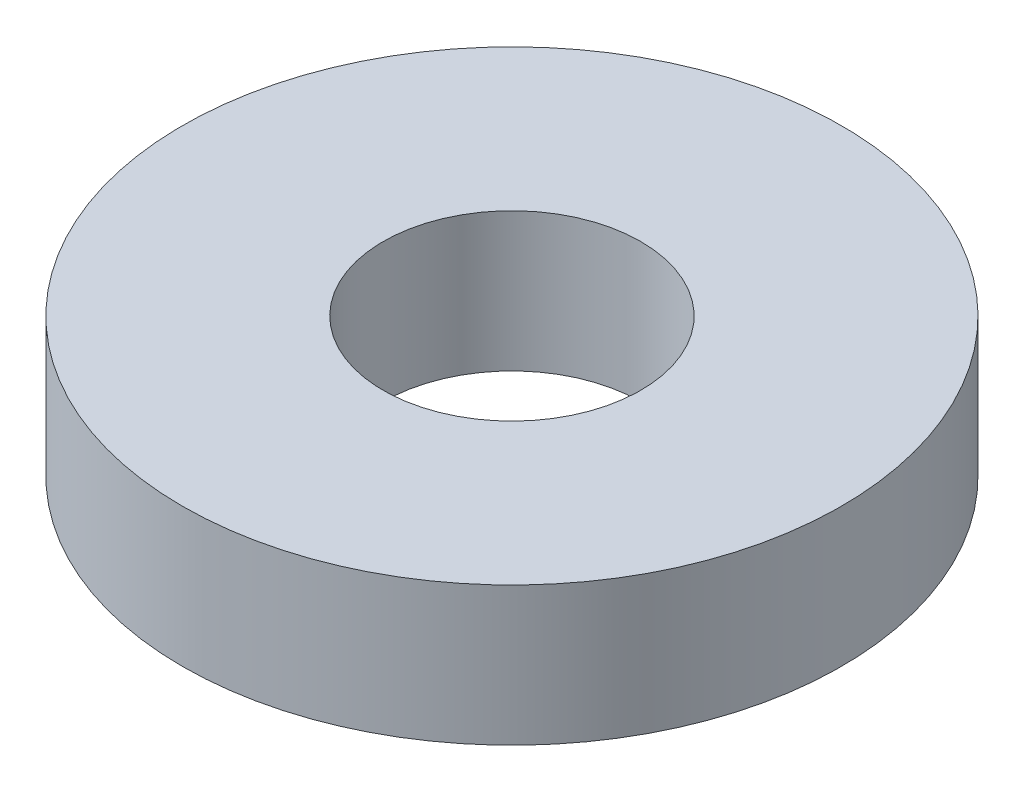
from build123d import *

# Parameters (mm, degrees)
SKETCH1_R           = 8.4455
BOSS_EXTRUDE1_DEPTH = 3.556
SKETCH2_R           = 3.302
CUT_EXTRUDE1_DEPTH  = 4.556


with BuildPart() as part:
    # Sketch1 → Boss-Extrude1 (new body)
    with BuildSketch(Plane(origin=(0, 0, 0), x_dir=(1, 0, 0), z_dir=(0, 1, 0))):
        Circle(SKETCH1_R)
    extrude(amount=BOSS_EXTRUDE1_DEPTH)

    # Sketch2 → Cut-Extrude1 (cut, through all)
    with BuildSketch(Plane(origin=(0, 0, 0), x_dir=(-1, 0, 0), z_dir=(0, -1, 0))):
        Circle(SKETCH2_R)
    extrude(amount=-CUT_EXTRUDE1_DEPTH, mode=Mode.SUBTRACT)


solid = part.part
